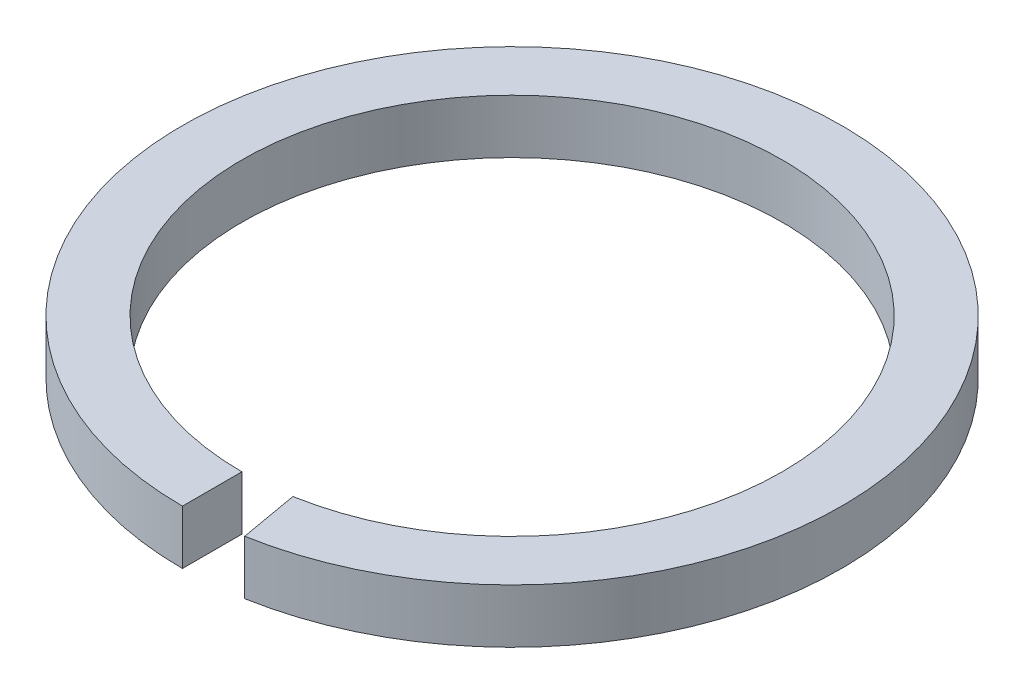
from build123d import *

# Parameters (mm, degrees)
SKETCH1_R      = 15.25
SKETCH1_R_2    = 12.5
EXTRUDE1_DEPTH = 2.5
EXTRUDE2_DEPTH = 3.5


with BuildPart() as part:
    # Sketch1 → Extrude1 (new body)
    with BuildSketch(Plane(origin=(0, 0, 0), x_dir=(1, 0, 0), z_dir=(0, 1, 0))):
        with Locations(Location((0, 0, 0), (0, 0, 270))):  # turned: the seam where the file's is
            Circle(SKETCH1_R)
        with Locations(Location((0, 0, 0), (0, 0, 270))):  # turned: the seam where the file's is
            Circle(SKETCH1_R_2, mode=Mode.SUBTRACT)
    extrude(amount=EXTRUDE1_DEPTH)

    # Sketch2 → Extrude2 (cut, through all)
    with BuildSketch(Plane(origin=(0, 2.5, 0), x_dir=(1, 0, 0), z_dir=(0, 1, 0))):
        with BuildLine():
            Line((0, -12.5), (0, -15.25))
            ThreePointArc((0, -15.25), (1.329125077, -15.191969146), (2.648134709, -15.018318233))
            Line((2.648134709, -15.018318233), (2.170602221, -12.310096913))
            ThreePointArc((2.170602221, -12.310096913), (1.089446784, -12.452433726), (0, -12.5))
        make_face()
    extrude(amount=-EXTRUDE2_DEPTH, mode=Mode.SUBTRACT)


solid = part.part
